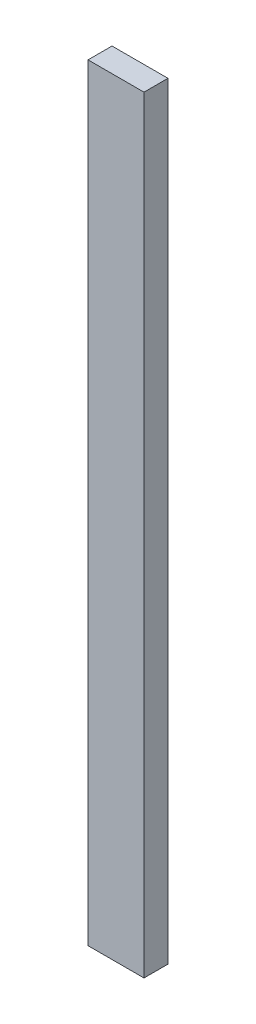
from build123d import *

# Parameters (mm, degrees)
SKETCH1_W           = 88.9
SKETCH1_H           = 38.1
BOSS_EXTRUDE1_DEPTH = 1219.2


with BuildPart() as part:
    # Sketch1 → Boss-Extrude1 (new body)
    with BuildSketch(Plane(origin=(0, 0, 0), x_dir=(1, 0, 0), z_dir=(0, 1, 0))):
        Rectangle(SKETCH1_W, SKETCH1_H)
    extrude(amount=BOSS_EXTRUDE1_DEPTH)


solid = part.part
